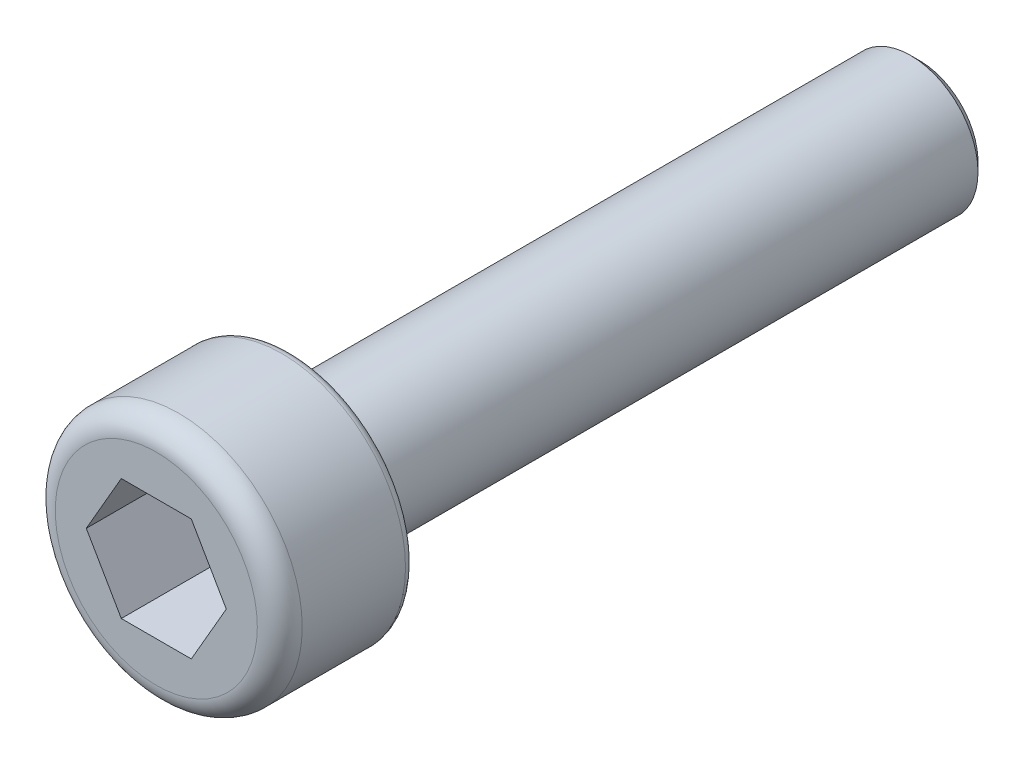
from build123d import *

# Parameters (mm, degrees)
SKETCH_1_R          = 2.75
EXTRUDE_1_DEPTH     = 3
FILLET_1_R          = 0.5
CUT_EXTRUDE_1_DEPTH = 2
SKETCH_3_R          = 1.5
EXTRUDE_2_DEPTH     = 14
CHAMFER_1_SIZE      = 0.2
FILLET_2_R          = 0.2


with BuildPart() as part:
    # 草图1 → 凸台-拉伸1 (new body)
    with BuildSketch(Plane.XY):
        Circle(SKETCH_1_R)
    extrude(amount=EXTRUDE_1_DEPTH)

    # 圆角1
    fillet_1_edges = [part.edges().sort_by_distance(p)[0] for p in [
        (-2.75, 0, 3),
    ]]
    fillet(fillet_1_edges, radius=FILLET_1_R)

    # 草图2 → 切除-拉伸1 (cut)
    with BuildSketch(Plane.XY.offset(3)):
        Polygon((1.558845727, 0), (0.779422863, 1.35), (-0.779422863, 1.35), (-1.558845727, 0), (-0.779422863, -1.35), (0.779422863, -1.35), align=None)
    extrude(amount=-CUT_EXTRUDE_1_DEPTH, mode=Mode.SUBTRACT)

    # 草图3 → 凸台-拉伸2 (add)
    with BuildSketch(Plane(origin=(0, 0, 0), x_dir=(-1, 0, 0), z_dir=(0, 0, -1))):
        Circle(SKETCH_3_R)
    extrude(amount=EXTRUDE_2_DEPTH)

    # 倒角1
    chamfer_1_edges = [part.edges().sort_by_distance(p)[0] for p in [
        (1.5, 0, -14),
    ]]
    chamfer(chamfer_1_edges, length=CHAMFER_1_SIZE)

    # 圆角2
    fillet_2_edges = [part.edges().sort_by_distance(p)[0] for p in [
        (-2.75, 0, 0),
    ]]
    fillet(fillet_2_edges, radius=FILLET_2_R)


solid = part.part
